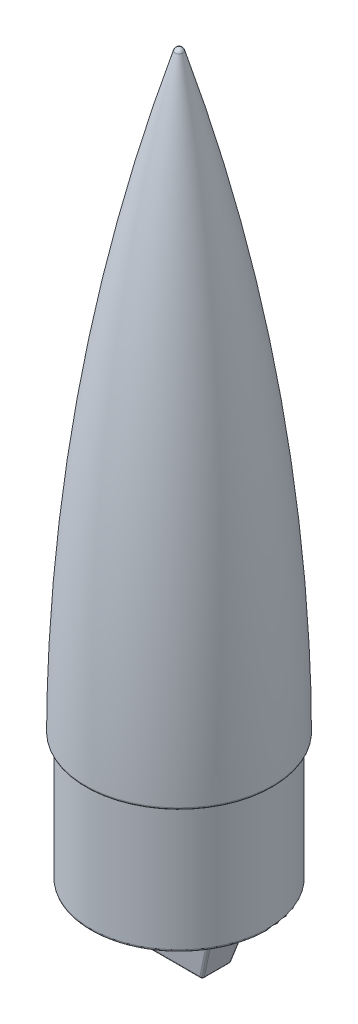
from build123d import *

# Parameters (mm, degrees)
CUT_EXTRUDE3_REACH             = 80.288
SKETCH6_W                      = 10
SKETCH6_H                      = 2.87
BOSS_EXTRUDE1_DEPTH            = 2.435
CUT_EXTRUDE1_DEPTH             = 79.287930228
CUT_EXTRUDE1_DEPTH_BACK        = 79.287930228
SKETCH4_R                      = 1.75
CUT_EXTRUDE2_DEPTH             = 79.287930228
CUT_EXTRUDE2_DEPTH_BACK        = 79.287930228
CUT_EXTRUDE4_REACH             = 80.288
CUT_EXTRUDE4_DIRECTION_2_REACH = 80.288
CUT_EXTRUDE5_REACH             = 80.288
FILLET2_R                      = 0.25


with BuildPart() as part:
    # Sketch1 → Revolve1 (revolve)
    with BuildSketch(Plane.XY, mode=Mode.PRIVATE) as revolve1_sk:
        with BuildLine():
            Line((0, 0), (-9.45, 0))
            Line((-9.45, 0), (-9.45, 13.5))
            Line((-9.45, 13.5), (-10, 13.5))
            ThreePointArc((-10, 13.5), (-7.518444553, 45.424017496), (-0.430495121, 76.65))
            ThreePointArc((-0.430495121, 76.65), (-0.268628402, 76.890657691), (0, 77))
            Line((0, 77), (0, 0))
        make_face()
    revolve(revolve1_sk.sketch.rotate(Axis((0, 80.276421337, 0), (0, -1, 0)), 270), axis=Axis((0, 80.276421337, 0), (0, -1, 0)))

    # Sketch5 → Cut-Revolve1 (revolve, cut)
    with BuildSketch(Plane.XY, mode=Mode.PRIVATE) as cut_revolve1_sk:
        with BuildLine():
            Line((0, 1), (-8.45, 1))
            Line((-8.45, 1), (-8.45, 14.5))
            Line((-8.45, 14.5), (-8.992921861, 14.5))
            ThreePointArc((-8.992921861, 14.5), (-6.591032475, 44.867083426), (0, 74.607411591))
            Line((0, 74.607411591), (0, 1))
        make_face()
    revolve(cut_revolve1_sk.sketch.rotate(Axis((0, -1.747604585, 0), (0, 1, 0)), 90), axis=Axis((0, -1.747604585, 0), (0, 1, 0)), mode=Mode.SUBTRACT)

    # Sketch6 → Cut-Extrude3 (cut, up to next)
    with BuildSketch(Plane.XZ, mode=Mode.PRIVATE) as cut_extrude3_sk1:
        Rectangle(SKETCH6_W, SKETCH6_H)
    cut_extrude3_tool1 = extrude(cut_extrude3_sk1.sketch, amount=-CUT_EXTRUDE3_REACH, mode=Mode.PRIVATE) & part.part
    add(cut_extrude3_tool1.solids().sort_by_distance((0, 0, 0))[0], mode=Mode.SUBTRACT)

    # Sketch2 → Boss-Extrude1 (add, symmetric)
    with BuildSketch(Plane.XY):
        Polygon((-6, 0), (6, 0), (4, -6.4), (-4, -6.4), align=None)
    extrude(amount=BOSS_EXTRUDE1_DEPTH, both=True)

    # Sketch3 → Cut-Extrude1 (cut, two sides)
    with BuildSketch(Plane(origin=(0, 0, 0), x_dir=(0, 0, -1), z_dir=(1, 0, 0))) as cut_extrude1_sk:
        Polygon((-1.565, -6.4), (-2.435, 0), (-2.435, -6.4), align=None)
        Polygon((2.435, -6.4), (1.565, -6.4), (2.435, 0), align=None)
    extrude(amount=CUT_EXTRUDE1_DEPTH, mode=Mode.SUBTRACT)
    extrude(cut_extrude1_sk.sketch, amount=-CUT_EXTRUDE1_DEPTH_BACK, mode=Mode.SUBTRACT)

    # Sketch4 → Cut-Extrude2 (cut, two sides)
    with BuildSketch(Plane.XY) as cut_extrude2_sk:
        with Locations(Location((0, -2.5, 0), (0, 0, 90))):
            Circle(SKETCH4_R)
    extrude(amount=CUT_EXTRUDE2_DEPTH, mode=Mode.SUBTRACT)
    extrude(cut_extrude2_sk.sketch, amount=-CUT_EXTRUDE2_DEPTH_BACK, mode=Mode.SUBTRACT)

    # Cut-Extrude4: up to this plane
    cut_extrude4_end = Plane(origin=(-10, -6.265301351, -0.57411339), z_dir=(0, 0.13469864856050326, 0.9908866101002547))
    # Sketch7 → Cut-Extrude4 (cut, up to the surface)
    with BuildSketch(Plane.XY, mode=Mode.PRIVATE) as cut_extrude4_sk1:
        with BuildLine():
            Line((1.145643924, 0), (5, 0))
            Line((5, 0), (3.3125, -5.4))
            Line((3.3125, -5.4), (-3.3125, -5.4))
            Line((-3.3125, -5.4), (-5, 0))
            Line((-5, 0), (-1.145643924, 0))
            ThreePointArc((-1.145643924, 0), (0, -5.25), (1.145643924, 0))
        make_face()
    cut_extrude4_tool1 = split(extrude(cut_extrude4_sk1.sketch, amount=-CUT_EXTRUDE4_REACH, mode=Mode.PRIVATE), bisect_by=cut_extrude4_end, keep=Keep.BOTH, mode=Mode.PRIVATE)
    add(cut_extrude4_tool1.solids().sort_by_distance((3.072822, -0.113649, 0))[0], mode=Mode.SUBTRACT)

    # Cut-Extrude4 direction 2: up to this plane
    cut_extrude4_direction_2_end = Plane(origin=(-10, -6.265301351, 0.57411339), z_dir=(0, 0.13469864856050348, -0.9908866101002546))
    # Sketch7 → Cut-Extrude4 direction 2 (cut, up to the surface)
    with BuildSketch(Plane.XY, mode=Mode.PRIVATE) as cut_extrude4_direction_2_sk1:
        with BuildLine():
            Line((1.145643924, 0), (5, 0))
            Line((5, 0), (3.3125, -5.4))
            Line((3.3125, -5.4), (-3.3125, -5.4))
            Line((-3.3125, -5.4), (-5, 0))
            Line((-5, 0), (-1.145643924, 0))
            ThreePointArc((-1.145643924, 0), (0, -5.25), (1.145643924, 0))
        make_face()
    cut_extrude4_direction_2_tool1 = split(extrude(cut_extrude4_direction_2_sk1.sketch, amount=CUT_EXTRUDE4_DIRECTION_2_REACH, mode=Mode.PRIVATE), bisect_by=cut_extrude4_direction_2_end, keep=Keep.BOTH, mode=Mode.PRIVATE)
    add(cut_extrude4_direction_2_tool1.solids().sort_by_distance((3.072822, -0.113649, 0))[0], mode=Mode.SUBTRACT)

    # Sketch8 → Cut-Extrude5 (cut, up to next)
    with BuildSketch(Plane.XZ, mode=Mode.PRIVATE) as cut_extrude5_sk1:
        with BuildLine():
            ThreePointArc((-7.858116823, 1.5), (-8, 0), (-7.858116823, -1.5))
            ThreePointArc((-7.858116823, -1.5), (-6.83744746, 0), (-7.858116823, 1.5))
        make_face()
    cut_extrude5_tool1 = extrude(cut_extrude5_sk1.sketch, amount=-CUT_EXTRUDE5_REACH, mode=Mode.PRIVATE) & part.part
    add(cut_extrude5_tool1.solids().sort_by_distance((-7.490592, 0, 0))[0], mode=Mode.SUBTRACT)

    # Fillet2
    fillet2_edges = [part.edges().sort_by_distance(p)[0] for p in [
        (-6.83744746, 0, 0),
        (-8, 0, 0),
        (-7.858116823, 0.5, -1.5),
        (-7.858116823, 0.5, 1.5),
        (-6, 0, 0),
        (0, 0, -2.435),
        (6, 0, 0),
        (0, 0, 2.435),
        (4, -6.4, 0),
        (-4, -6.4, 0),
        (0, -6.4, 1.565),
        (-5, -3.2, 2),
        (5, -3.2, 2),
        (0, 13.5, -10),
        (0, 13.5, -9.45),
        (0, 0, -9.45),
        (-5, -3.2, -2),
        (0, -6.4, -1.565),
        (5, -3.2, -2),
        (4e-08, -4.25, -1.857265625),
        (4e-08, -4.25, 1.857265625),
    ]]
    fillet(fillet2_edges, radius=FILLET2_R)


solid = part.part
